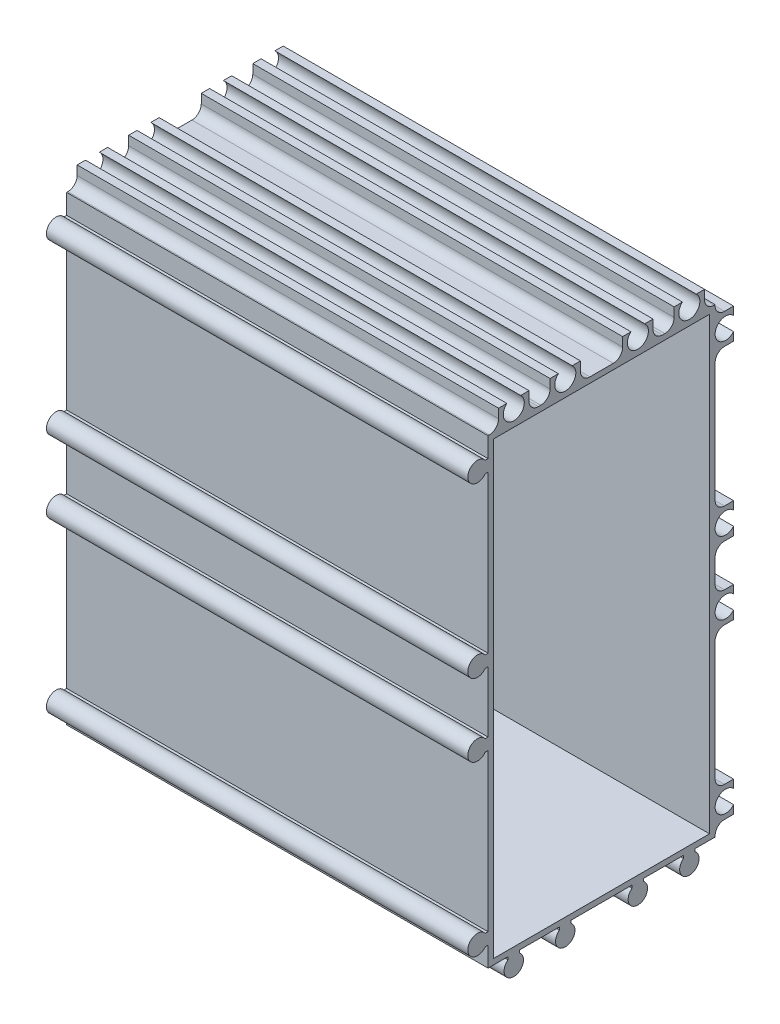
from build123d import *

# Parameters (mm, degrees)
EXTRUDE_1_DEPTH             = 90
SKETCH_2_W                  = 90
SKETCH_2_H                  = 44.25
EXTRUDE_2_DEPTH             = 8.2
SKETCH_3_W                  = 90
SKETCH_3_H                  = 102.45
EXTRUDE_3_DEPTH             = 8.2
SKETCH_4_W                  = 4.5
SKETCH_4_H                  = 3.95
CUT_EXTRUDE_1_DEPTH         = 91
SKETCH_5_W                  = 2.25
SKETCH_5_H                  = 3.95
CUT_EXTRUDE_2_DEPTH         = 91
SKETCH_6_W                  = 3.95
SKETCH_6_H                  = 2.25
CUT_EXTRUDE_3_DEPTH         = 91
SKETCH_7_W                  = 3.95
SKETCH_7_H                  = 29.5
CUT_EXTRUDE_4_DEPTH         = 91
SKETCH_8_W                  = 3.95
SKETCH_8_H                  = 9
CUT_EXTRUDE_5_DEPTH         = 91
SKETCH_9_W                  = 3.95
SKETCH_9_H                  = 29.5
CUT_EXTRUDE_6_DEPTH         = 91
SKETCH_10_W                 = 3.95
SKETCH_10_H                 = 6.2
CUT_EXTRUDE_7_DEPTH         = 91
SKETCH_11_W                 = 2.25
SKETCH_11_H                 = 3.95
CUT_EXTRUDE_8_DEPTH         = 91
SKETCH_12_W                 = 4.5
SKETCH_12_H                 = 3.95
CUT_EXTRUDE_9_DEPTH         = 91
SKETCH_13_W                 = 9
SKETCH_13_H                 = 3.95
CUT_EXTRUDE_10_DEPTH        = 91
SKETCH_14_W                 = 46.1
SKETCH_14_H                 = 96.1
CUT_EXTRUDE_11_DEPTH        = 86.6
HOLE_WIZARD_2_5_2_5_1_D     = 2.5
HOLE_WIZARD_2_5_2_5_1_DEPTH = 90
HOLE_WIZARD_4_5_4_5_1_D     = 4.5
HOLE_WIZARD_4_5_4_5_1_DEPTH = 90
SKETCH_22_R                 = 1.631577579
SKETCH_22_R_2               = 1.519375383
SKETCH_22_R_3               = 1.487580747
SKETCH_22_R_4               = 1.581735942
SKETCH_22_R_5               = 1.487835557
SKETCH_22_R_6               = 1.42600834
SKETCH_22_R_7               = 1.628129915
SKETCH_22_R_8               = 1.52367125
EXTRUDE_4_DEPTH             = 90
FILLET_5_R                  = 2
FILLET_6_R                  = 2
FILLET_7_R                  = 2
FILLET_8_R                  = 2
FILLET_9_R                  = 2
FILLET_10_R                 = 2
FILLET_11_R                 = 2
FILLET_12_R                 = 2
FILLET_13_R                 = 2
FILLET_14_R                 = 2
FILLET_15_R                 = 2
FILLET_16_R                 = 2
FILLET_17_R                 = 2
FILLET_18_R                 = 2
FILLET_19_R                 = 2
FILLET_20_R                 = 2


with BuildPart() as part:
    # Эскиз1 → Бобышка-Вытянуть1 (new body)
    with BuildSketch(Plane(origin=(90, 0, 0), x_dir=(0, 0, -1), z_dir=(1, 0, 0))):
        with BuildLine():
            Line((6.75, 225.906238208), (6.75, 320.75))
            Line((6.75, 320.75), (-38.093761792, 320.75))
            ThreePointArc((-38.093761792, 320.75), (-41.825, 319.5), (-38.093761792, 318.25))
            Line((-38.093761792, 318.25), (-37.5, 318.25))
            Line((-37.5, 318.25), (-37.5, 284.75))
            Line((-37.5, 284.75), (-38.093761792, 284.75))
            ThreePointArc((-38.093761792, 284.75), (-41.825, 283.5), (-38.093761792, 282.25))
            Line((-38.093761792, 282.25), (-37.5, 282.25))
            Line((-37.5, 282.25), (-37.5, 269.25))
            Line((-37.5, 269.25), (-38.093761792, 269.25))
            ThreePointArc((-38.093761792, 269.25), (-41.825, 268), (-38.093761792, 266.75))
            Line((-38.093761792, 266.75), (-37.5, 266.75))
            Line((-37.5, 266.75), (-37.5, 233.25))
            Line((-37.5, 233.25), (-38.093761792, 233.25))
            ThreePointArc((-38.093761792, 233.25), (-41.825, 232), (-38.093761792, 230.75))
            Line((-38.093761792, 230.75), (-37.5, 230.75))
            Line((-37.5, 230.75), (-37.5, 226.5))
            Line((-37.5, 226.5), (-33.25, 226.5))
            Line((-33.25, 226.5), (-33.25, 225.906238208))
            ThreePointArc((-33.25, 225.906238208), (-32, 222.175), (-30.75, 225.906238208))
            Line((-30.75, 225.906238208), (-30.75, 226.5))
            Line((-30.75, 226.5), (-22.25, 226.5))
            Line((-22.25, 226.5), (-22.25, 225.906238208))
            ThreePointArc((-22.25, 225.906238208), (-21, 222.175), (-19.75, 225.906238208))
            Line((-19.75, 225.906238208), (-19.75, 226.5))
            Line((-19.75, 226.5), (-6.75, 226.5))
            Line((-6.75, 226.5), (-6.75, 225.906238208))
            ThreePointArc((-6.75, 225.906238208), (-5.5, 222.175), (-4.25, 225.906238208))
            Line((-4.25, 225.906238208), (-4.25, 226.5))
            Line((-4.25, 226.5), (4.25, 226.5))
            Line((4.25, 226.5), (4.25, 225.906238208))
            ThreePointArc((4.25, 225.906238208), (5.5, 222.175), (6.75, 225.906238208))
        make_face()
    extrude(amount=-EXTRUDE_1_DEPTH)

    # Эскиз2 → Бобышка-Вытянуть2 (add)
    with BuildSketch(Plane(origin=(0, 320.75, 0), x_dir=(-1, 0, 0), z_dir=(0, 1, 0))):
        with Locations((-45, 15.375)):
            Rectangle(SKETCH_2_W, SKETCH_2_H)
    extrude(amount=EXTRUDE_2_DEPTH)

    # Эскиз3 → Бобышка-Вытянуть3 (add)
    with BuildSketch(Plane(origin=(0, 0, -6.75), x_dir=(-1, 0, 0), z_dir=(0, 0, -1))):
        with Locations((-45, 277.725)):
            Rectangle(SKETCH_3_W, SKETCH_3_H)
    extrude(amount=EXTRUDE_3_DEPTH)

    # Эскиз4 → Вырез-Вытянуть1 (cut, through all)
    with BuildSketch(Plane.ZY):
        with Locations((26.5, 326.975)):
            Rectangle(SKETCH_4_W, SKETCH_4_H)
    extrude(amount=-CUT_EXTRUDE_1_DEPTH, mode=Mode.SUBTRACT)

    # Эскиз5 → Вырез-Вытянуть2 (cut, through all)
    with BuildSketch(Plane.ZY):
        with Locations((36.375, 326.975)):
            Rectangle(SKETCH_5_W, SKETCH_5_H)
    extrude(amount=-CUT_EXTRUDE_2_DEPTH, mode=Mode.SUBTRACT)

    # Эскиз6 → Вырез-Вытянуть3 (cut, through all)
    with BuildSketch(Plane.ZY):
        with Locations((-12.975, 227.625)):
            Rectangle(SKETCH_6_W, SKETCH_6_H)
    extrude(amount=-CUT_EXTRUDE_3_DEPTH, mode=Mode.SUBTRACT)

    # Эскиз7 → Вырез-Вытянуть4 (cut, through all)
    with BuildSketch(Plane.ZY):
        with Locations((-12.975, 250)):
            Rectangle(SKETCH_7_W, SKETCH_7_H)
    extrude(amount=-CUT_EXTRUDE_4_DEPTH, mode=Mode.SUBTRACT)

    # Эскиз8 → Вырез-Вытянуть5 (cut, through all)
    with BuildSketch(Plane.ZY):
        with Locations((-12.975, 275.75)):
            Rectangle(SKETCH_8_W, SKETCH_8_H)
    extrude(amount=-CUT_EXTRUDE_5_DEPTH, mode=Mode.SUBTRACT)

    # Эскиз9 → Вырез-Вытянуть6 (cut, through all)
    with BuildSketch(Plane.ZY):
        with Locations((-12.975, 301.5)):
            Rectangle(SKETCH_9_W, SKETCH_9_H)
    extrude(amount=-CUT_EXTRUDE_6_DEPTH, mode=Mode.SUBTRACT)

    # Эскиз10 → Вырез-Вытянуть7 (cut, through all)
    with BuildSketch(Plane.ZY):
        with Locations((-12.975, 325.85)):
            Rectangle(SKETCH_10_W, SKETCH_10_H)
    extrude(amount=-CUT_EXTRUDE_7_DEPTH, mode=Mode.SUBTRACT)

    # Эскиз11 → Вырез-Вытянуть8 (cut, through all)
    with BuildSketch(Plane.ZY):
        with Locations((-9.875, 326.975)):
            Rectangle(SKETCH_11_W, SKETCH_11_H)
    extrude(amount=-CUT_EXTRUDE_8_DEPTH, mode=Mode.SUBTRACT)

    # Эскиз12 → Вырез-Вытянуть9 (cut, through all)
    with BuildSketch(Plane.ZY):
        with Locations((0, 326.975)):
            Rectangle(SKETCH_12_W, SKETCH_12_H)
    extrude(amount=-CUT_EXTRUDE_9_DEPTH, mode=Mode.SUBTRACT)

    # Эскиз13 → Вырез-Вытянуть10 (cut, through all)
    with BuildSketch(Plane.ZY):
        with Locations((13.25, 326.975)):
            Rectangle(SKETCH_13_W, SKETCH_13_H)
    extrude(amount=-CUT_EXTRUDE_10_DEPTH, mode=Mode.SUBTRACT)

    # Эскиз14 → Вырез-Вытянуть11 (cut)
    with BuildSketch(Plane(origin=(90, 0, 0), x_dir=(0, 0, -1), z_dir=(1, 0, 0))):
        with Locations((-13.25, 275.75)):
            Rectangle(SKETCH_14_W, SKETCH_14_H)
    extrude(amount=-CUT_EXTRUDE_11_DEPTH, mode=Mode.SUBTRACT)

    # Диаметр отверстия Ø2.5 (2.5)1
    with Locations(Plane(origin=(90, 0, 0), x_dir=(0, 0, -1), z_dir=(1, 0, 0))):
        with Locations((-39.75, 232), (-21, 224.25), (-39.75, 283.5), (-5.5, 224.25), (5.5, 224.25), (-39.75, 319.5), (-39.75, 268), (-32, 224.25)):
            Hole(HOLE_WIZARD_2_5_2_5_1_D / 2, depth=HOLE_WIZARD_2_5_2_5_1_DEPTH)

    # Диаметр отверстия Ø4.5 (4.5)1
    with Locations(Plane.ZY):
        with Locations((21, 327.25), (32, 327.25), (-13.25, 232), (-13.25, 268), (-13.25, 283.5), (-13.25, 319.5), (-5.5, 327.25), (5.5, 327.25)):
            Hole(HOLE_WIZARD_4_5_4_5_1_D / 2, depth=HOLE_WIZARD_4_5_4_5_1_DEPTH)

    # Эскиз22 → Бобышка-Вытянуть4 (add)
    with BuildSketch(Plane(origin=(90, 0, 0), x_dir=(0, 0, -1), z_dir=(1, 0, 0))):
        with Locations((-39.75, 319.5)):
            Circle(SKETCH_22_R)
        with Locations((-39.75, 283.5)):
            Circle(SKETCH_22_R_2)
        with Locations((-39.75, 268)):
            Circle(SKETCH_22_R_3)
        with Locations((-39.75, 232)):
            Circle(SKETCH_22_R_4)
        with Locations((-32, 224.25)):
            Circle(SKETCH_22_R_5)
        with Locations((-21, 224.25)):
            Circle(SKETCH_22_R_6)
        with Locations((-5.5, 224.25)):
            Circle(SKETCH_22_R_7)
        with Locations((5.5, 224.25)):
            Circle(SKETCH_22_R_8)
    extrude(amount=-EXTRUDE_4_DEPTH)

    # Скругление5
    fillet_5_edges = [part.edges().sort_by_distance(p)[0] for p in [
        (45, 325, 35.25),
    ]]
    fillet(fillet_5_edges, radius=FILLET_5_R)

    # Скругление6
    fillet_6_edges = [part.edges().sort_by_distance(p)[0] for p in [
        (45, 325, 28.75),
    ]]
    fillet(fillet_6_edges, radius=FILLET_6_R)

    # Скругление7
    fillet_7_edges = [part.edges().sort_by_distance(p)[0] for p in [
        (45, 325, 24.25),
    ]]
    fillet(fillet_7_edges, radius=FILLET_7_R)

    # Скругление8
    fillet_8_edges = [part.edges().sort_by_distance(p)[0] for p in [
        (45, 325, 17.75),
    ]]
    fillet(fillet_8_edges, radius=FILLET_8_R)

    # Скругление9
    fillet_9_edges = [part.edges().sort_by_distance(p)[0] for p in [
        (45, 325, 8.75),
    ]]
    fillet(fillet_9_edges, radius=FILLET_9_R)

    # Скругление10
    fillet_10_edges = [part.edges().sort_by_distance(p)[0] for p in [
        (45, 325, 2.25),
    ]]
    fillet(fillet_10_edges, radius=FILLET_10_R)

    # Скругление11
    fillet_11_edges = [part.edges().sort_by_distance(p)[0] for p in [
        (45, 325, -2.25),
    ]]
    fillet(fillet_11_edges, radius=FILLET_11_R)

    # Скругление12
    fillet_12_edges = [part.edges().sort_by_distance(p)[0] for p in [
        (45, 325, -8.75),
    ]]
    fillet(fillet_12_edges, radius=FILLET_12_R)

    # Скругление13
    fillet_13_edges = [part.edges().sort_by_distance(p)[0] for p in [
        (45, 322.75, -11),
    ]]
    fillet(fillet_13_edges, radius=FILLET_13_R)

    # Скругление14
    fillet_14_edges = [part.edges().sort_by_distance(p)[0] for p in [
        (45, 316.25, -11),
    ]]
    fillet(fillet_14_edges, radius=FILLET_14_R)

    # Скругление15
    fillet_15_edges = [part.edges().sort_by_distance(p)[0] for p in [
        (45, 286.75, -11),
    ]]
    fillet(fillet_15_edges, radius=FILLET_15_R)

    # Скругление16
    fillet_16_edges = [part.edges().sort_by_distance(p)[0] for p in [
        (45, 280.25, -11),
    ]]
    fillet(fillet_16_edges, radius=FILLET_16_R)

    # Скругление17
    fillet_17_edges = [part.edges().sort_by_distance(p)[0] for p in [
        (45, 271.25, -11),
    ]]
    fillet(fillet_17_edges, radius=FILLET_17_R)

    # Скругление18
    fillet_18_edges = [part.edges().sort_by_distance(p)[0] for p in [
        (45, 264.75, -11),
    ]]
    fillet(fillet_18_edges, radius=FILLET_18_R)

    # Скругление19
    fillet_19_edges = [part.edges().sort_by_distance(p)[0] for p in [
        (45, 235.25, -11),
    ]]
    fillet(fillet_19_edges, radius=FILLET_19_R)

    # Скругление20
    fillet_20_edges = [part.edges().sort_by_distance(p)[0] for p in [
        (45, 228.75, -11),
    ]]
    fillet(fillet_20_edges, radius=FILLET_20_R)


solid = part.part
